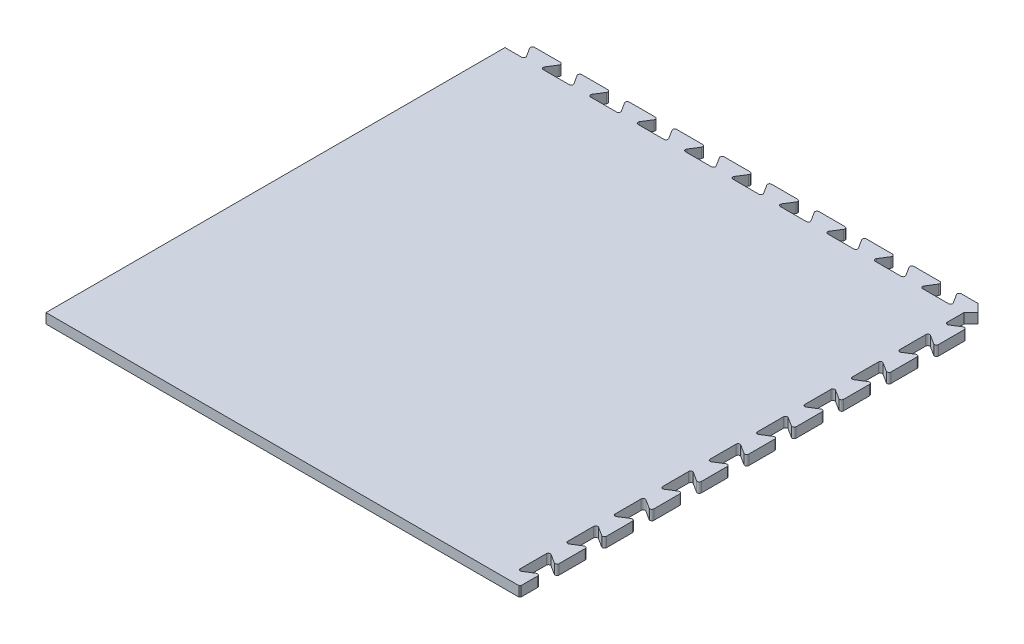
from build123d import *

# Parameters (mm, degrees)
BOSS_EXTRUDE1_DEPTH = 12.7


with BuildPart() as part:
    # Sketch1 → Boss-Extrude1 (new body)
    with BuildSketch(Plane(origin=(0, 12.7, 0), x_dir=(1, 0, 0), z_dir=(0, 1, 0))):
        with BuildLine():
            Line((-270.60420808, 291.891368192), (-291.891368192, 291.891368192))
            Line((-291.891368192, 291.891368192), (-291.891368192, -291.891368192))
            Line((-291.891368192, -291.891368192), (309.78579192, -291.891368192))
            Line((309.78579192, -291.891368192), (310.941368192, -290.73579192))
            Line((310.941368192, -290.73579192), (310.941368192, -269.46329192))
            ThreePointArc((310.941368192, -269.46329192), (309.624423913, -267.237143968), (307.039214883, -267.319431298))
            Line((307.039214883, -267.319431298), (295.793521501, -274.464652541))
            ThreePointArc((295.793521501, -274.464652541), (293.208312471, -274.546939871), (291.891368192, -272.32079192))
            Line((291.891368192, -272.32079192), (291.891368192, -239.30079192))
            ThreePointArc((291.891368192, -239.30079192), (293.208312471, -237.074643968), (295.793521501, -237.156931298))
            Line((295.793521501, -237.156931298), (307.039214883, -244.302152541))
            ThreePointArc((307.039214883, -244.302152541), (309.624423913, -244.384439871), (310.941368192, -242.15829192))
            Line((310.941368192, -242.15829192), (310.941368192, -209.13829192))
            ThreePointArc((310.941368192, -209.13829192), (309.624423913, -206.912143968), (307.039214883, -206.994431298))
            Line((307.039214883, -206.994431298), (295.793521501, -214.139652541))
            ThreePointArc((295.793521501, -214.139652541), (293.208312471, -214.221939871), (291.891368192, -211.99579192))
            Line((291.891368192, -211.99579192), (291.891368192, -178.97579192))
            ThreePointArc((291.891368192, -178.97579192), (293.208312471, -176.749643968), (295.793521501, -176.831931298))
            Line((295.793521501, -176.831931298), (307.039214883, -183.977152541))
            ThreePointArc((307.039214883, -183.977152541), (309.624423913, -184.059439871), (310.941368192, -181.83329192))
            Line((310.941368192, -181.83329192), (310.941368192, -148.81329192))
            ThreePointArc((310.941368192, -148.81329192), (309.624423913, -146.587143968), (307.039214883, -146.669431298))
            Line((307.039214883, -146.669431298), (295.793521501, -153.814652541))
            ThreePointArc((295.793521501, -153.814652541), (293.208312471, -153.896939871), (291.891368192, -151.67079192))
            Line((291.891368192, -151.67079192), (291.891368192, -118.65079192))
            ThreePointArc((291.891368192, -118.65079192), (293.208312471, -116.424643968), (295.793521501, -116.506931298))
            Line((295.793521501, -116.506931298), (307.039214883, -123.652152541))
            ThreePointArc((307.039214883, -123.652152541), (309.624423913, -123.734439871), (310.941368192, -121.50829192))
            Line((310.941368192, -121.50829192), (310.941368192, -88.48829192))
            ThreePointArc((310.941368192, -88.48829192), (309.624423913, -86.262143968), (307.039214883, -86.344431298))
            Line((307.039214883, -86.344431298), (295.793521501, -93.489652541))
            ThreePointArc((295.793521501, -93.489652541), (293.208312471, -93.571939871), (291.891368192, -91.34579192))
            Line((291.891368192, -91.34579192), (291.891368192, -58.32579192))
            ThreePointArc((291.891368192, -58.32579192), (293.208312471, -56.099643968), (295.793521501, -56.181931298))
            Line((295.793521501, -56.181931298), (307.039214883, -63.327152541))
            ThreePointArc((307.039214883, -63.327152541), (309.624423913, -63.409439871), (310.941368192, -61.18329192))
            Line((310.941368192, -61.18329192), (310.941368192, -28.16329192))
            ThreePointArc((310.941368192, -28.16329192), (309.624423913, -25.937143968), (307.039214883, -26.019431298))
            Line((307.039214883, -26.019431298), (295.793521501, -33.164652541))
            ThreePointArc((295.793521501, -33.164652541), (293.208312471, -33.246939871), (291.891368192, -31.02079192))
            Line((291.891368192, -31.02079192), (291.891368192, 1.99920808))
            ThreePointArc((291.891368192, 1.99920808), (293.208312471, 4.225356032), (295.793521501, 4.143068702))
            Line((295.793521501, 4.143068702), (307.039214883, -3.002152541))
            ThreePointArc((307.039214883, -3.002152541), (309.624423913, -3.084439871), (310.941368192, -0.85829192))
            Line((310.941368192, -0.85829192), (310.941368192, 32.16170808))
            ThreePointArc((310.941368192, 32.16170808), (309.624423913, 34.387856032), (307.039214883, 34.305568702))
            Line((307.039214883, 34.305568702), (295.793521501, 27.160347459))
            ThreePointArc((295.793521501, 27.160347459), (293.208312471, 27.078060129), (291.891368192, 29.30420808))
            Line((291.891368192, 29.30420808), (291.891368192, 62.32420808))
            ThreePointArc((291.891368192, 62.32420808), (293.208312471, 64.550356032), (295.793521501, 64.468068702))
            Line((295.793521501, 64.468068702), (307.039214883, 57.322847459))
            ThreePointArc((307.039214883, 57.322847459), (309.624423913, 57.240560129), (310.941368192, 59.46670808))
            Line((310.941368192, 59.46670808), (310.941368192, 92.48670808))
            ThreePointArc((310.941368192, 92.48670808), (309.624423913, 94.712856032), (307.039214883, 94.630568702))
            Line((307.039214883, 94.630568702), (295.793521501, 87.485347459))
            ThreePointArc((295.793521501, 87.485347459), (293.208312471, 87.403060129), (291.891368192, 89.62920808))
            Line((291.891368192, 89.62920808), (291.891368192, 122.64920808))
            ThreePointArc((291.891368192, 122.64920808), (293.208312471, 124.875356032), (295.793521501, 124.793068702))
            Line((295.793521501, 124.793068702), (307.039214883, 117.647847459))
            ThreePointArc((307.039214883, 117.647847459), (309.624423913, 117.565560129), (310.941368192, 119.79170808))
            Line((310.941368192, 119.79170808), (310.941368192, 152.81170808))
            ThreePointArc((310.941368192, 152.81170808), (309.624423913, 155.037856032), (307.039214883, 154.955568702))
            Line((307.039214883, 154.955568702), (295.793521501, 147.810347459))
            ThreePointArc((295.793521501, 147.810347459), (293.208312471, 147.728060129), (291.891368192, 149.95420808))
            Line((291.891368192, 149.95420808), (291.891368192, 182.97420808))
            ThreePointArc((291.891368192, 182.97420808), (293.208312471, 185.200356032), (295.793521501, 185.118068702))
            Line((295.793521501, 185.118068702), (307.039214883, 177.972847459))
            ThreePointArc((307.039214883, 177.972847459), (309.624423913, 177.890560129), (310.941368192, 180.11670808))
            Line((310.941368192, 180.11670808), (310.941368192, 213.13670808))
            ThreePointArc((310.941368192, 213.13670808), (309.624423913, 215.362856032), (307.039214883, 215.280568702))
            Line((307.039214883, 215.280568702), (295.793521501, 208.135347459))
            ThreePointArc((295.793521501, 208.135347459), (293.208312471, 208.053060129), (291.891368192, 210.27920808))
            Line((291.891368192, 210.27920808), (291.891368192, 243.29920808))
            ThreePointArc((291.891368192, 243.29920808), (293.208312471, 245.525356032), (295.793521501, 245.443068702))
            Line((295.793521501, 245.443068702), (307.039214883, 238.297847459))
            ThreePointArc((307.039214883, 238.297847459), (309.624423913, 238.215560129), (310.941368192, 240.44170808))
            Line((310.941368192, 240.44170808), (310.941368192, 273.46170808))
            ThreePointArc((310.941368192, 273.46170808), (309.624423913, 275.687856032), (307.039214883, 275.605568702))
            Line((307.039214883, 275.605568702), (295.793521501, 268.460347459))
            ThreePointArc((295.793521501, 268.460347459), (293.208312471, 268.378060129), (291.891368192, 270.60420808))
            Line((291.891368192, 270.60420808), (291.891368192, 291.891368192))
            Line((291.891368192, 291.891368192), (300.838580056, 300.838580056))
            Line((300.838580056, 300.838580056), (290.73579192, 310.941368192))
            Line((290.73579192, 310.941368192), (269.46329192, 310.941368192))
            ThreePointArc((269.46329192, 310.941368192), (267.237143968, 309.624423913), (267.319431298, 307.039214883))
            Line((267.319431298, 307.039214883), (274.464652541, 295.793521501))
            ThreePointArc((274.464652541, 295.793521501), (274.546939871, 293.208312471), (272.32079192, 291.891368192))
            Line((272.32079192, 291.891368192), (239.30079192, 291.891368192))
            ThreePointArc((239.30079192, 291.891368192), (237.074643968, 293.208312471), (237.156931298, 295.793521501))
            Line((237.156931298, 295.793521501), (244.302152541, 307.039214883))
            ThreePointArc((244.302152541, 307.039214883), (244.384439871, 309.624423913), (242.15829192, 310.941368192))
            Line((242.15829192, 310.941368192), (209.13829192, 310.941368192))
            ThreePointArc((209.13829192, 310.941368192), (206.912143968, 309.624423913), (206.994431298, 307.039214883))
            Line((206.994431298, 307.039214883), (214.139652541, 295.793521501))
            ThreePointArc((214.139652541, 295.793521501), (214.221939871, 293.208312471), (211.99579192, 291.891368192))
            Line((211.99579192, 291.891368192), (178.97579192, 291.891368192))
            ThreePointArc((178.97579192, 291.891368192), (176.749643968, 293.208312471), (176.831931298, 295.793521501))
            Line((176.831931298, 295.793521501), (183.977152541, 307.039214883))
            ThreePointArc((183.977152541, 307.039214883), (184.059439871, 309.624423913), (181.83329192, 310.941368192))
            Line((181.83329192, 310.941368192), (148.81329192, 310.941368192))
            ThreePointArc((148.81329192, 310.941368192), (146.587143968, 309.624423913), (146.669431298, 307.039214883))
            Line((146.669431298, 307.039214883), (153.814652541, 295.793521501))
            ThreePointArc((153.814652541, 295.793521501), (153.896939871, 293.208312471), (151.67079192, 291.891368192))
            Line((151.67079192, 291.891368192), (118.65079192, 291.891368192))
            ThreePointArc((118.65079192, 291.891368192), (116.424643968, 293.208312471), (116.506931298, 295.793521501))
            Line((116.506931298, 295.793521501), (123.652152541, 307.039214883))
            ThreePointArc((123.652152541, 307.039214883), (123.734439871, 309.624423913), (121.50829192, 310.941368192))
            Line((121.50829192, 310.941368192), (88.48829192, 310.941368192))
            ThreePointArc((88.48829192, 310.941368192), (86.262143968, 309.624423913), (86.344431298, 307.039214883))
            Line((86.344431298, 307.039214883), (93.489652541, 295.793521501))
            ThreePointArc((93.489652541, 295.793521501), (93.571939871, 293.208312471), (91.34579192, 291.891368192))
            Line((91.34579192, 291.891368192), (58.32579192, 291.891368192))
            ThreePointArc((58.32579192, 291.891368192), (56.099643968, 293.208312471), (56.181931298, 295.793521501))
            Line((56.181931298, 295.793521501), (63.327152541, 307.039214883))
            ThreePointArc((63.327152541, 307.039214883), (63.409439871, 309.624423913), (61.18329192, 310.941368192))
            Line((61.18329192, 310.941368192), (28.16329192, 310.941368192))
            ThreePointArc((28.16329192, 310.941368192), (25.937143968, 309.624423913), (26.019431298, 307.039214883))
            Line((26.019431298, 307.039214883), (33.164652541, 295.793521501))
            ThreePointArc((33.164652541, 295.793521501), (33.246939871, 293.208312471), (31.02079192, 291.891368192))
            Line((31.02079192, 291.891368192), (-1.99920808, 291.891368192))
            ThreePointArc((-1.99920808, 291.891368192), (-4.225356032, 293.208312471), (-4.143068702, 295.793521501))
            Line((-4.143068702, 295.793521501), (3.002152541, 307.039214883))
            ThreePointArc((3.002152541, 307.039214883), (3.084439871, 309.624423913), (0.85829192, 310.941368192))
            Line((0.85829192, 310.941368192), (-32.16170808, 310.941368192))
            ThreePointArc((-32.16170808, 310.941368192), (-34.387856032, 309.624423913), (-34.305568702, 307.039214883))
            Line((-34.305568702, 307.039214883), (-27.160347459, 295.793521501))
            ThreePointArc((-27.160347459, 295.793521501), (-27.078060129, 293.208312471), (-29.30420808, 291.891368192))
            Line((-29.30420808, 291.891368192), (-62.32420808, 291.891368192))
            ThreePointArc((-62.32420808, 291.891368192), (-64.550356032, 293.208312471), (-64.468068702, 295.793521501))
            Line((-64.468068702, 295.793521501), (-57.322847459, 307.039214883))
            ThreePointArc((-57.322847459, 307.039214883), (-57.240560129, 309.624423913), (-59.46670808, 310.941368192))
            Line((-59.46670808, 310.941368192), (-92.48670808, 310.941368192))
            ThreePointArc((-92.48670808, 310.941368192), (-94.712856032, 309.624423913), (-94.630568702, 307.039214883))
            Line((-94.630568702, 307.039214883), (-87.485347459, 295.793521501))
            ThreePointArc((-87.485347459, 295.793521501), (-87.403060129, 293.208312471), (-89.62920808, 291.891368192))
            Line((-89.62920808, 291.891368192), (-122.64920808, 291.891368192))
            ThreePointArc((-122.64920808, 291.891368192), (-124.875356032, 293.208312471), (-124.793068702, 295.793521501))
            Line((-124.793068702, 295.793521501), (-117.647847459, 307.039214883))
            ThreePointArc((-117.647847459, 307.039214883), (-117.565560129, 309.624423913), (-119.79170808, 310.941368192))
            Line((-119.79170808, 310.941368192), (-152.81170808, 310.941368192))
            ThreePointArc((-152.81170808, 310.941368192), (-155.037856032, 309.624423913), (-154.955568702, 307.039214883))
            Line((-154.955568702, 307.039214883), (-147.810347459, 295.793521501))
            ThreePointArc((-147.810347459, 295.793521501), (-147.728060129, 293.208312471), (-149.95420808, 291.891368192))
            Line((-149.95420808, 291.891368192), (-182.97420808, 291.891368192))
            ThreePointArc((-182.97420808, 291.891368192), (-185.200356032, 293.208312471), (-185.118068702, 295.793521501))
            Line((-185.118068702, 295.793521501), (-177.972847459, 307.039214883))
            ThreePointArc((-177.972847459, 307.039214883), (-177.890560129, 309.624423913), (-180.11670808, 310.941368192))
            Line((-180.11670808, 310.941368192), (-213.13670808, 310.941368192))
            ThreePointArc((-213.13670808, 310.941368192), (-215.362856032, 309.624423913), (-215.280568702, 307.039214883))
            Line((-215.280568702, 307.039214883), (-208.135347459, 295.793521501))
            ThreePointArc((-208.135347459, 295.793521501), (-208.053060129, 293.208312471), (-210.27920808, 291.891368192))
            Line((-210.27920808, 291.891368192), (-243.29920808, 291.891368192))
            ThreePointArc((-243.29920808, 291.891368192), (-245.525356032, 293.208312471), (-245.443068702, 295.793521501))
            Line((-245.443068702, 295.793521501), (-238.297847459, 307.039214883))
            ThreePointArc((-238.297847459, 307.039214883), (-238.215560129, 309.624423913), (-240.44170808, 310.941368192))
            Line((-240.44170808, 310.941368192), (-273.46170808, 310.941368192))
            ThreePointArc((-273.46170808, 310.941368192), (-275.687856032, 309.624423913), (-275.605568702, 307.039214883))
            Line((-275.605568702, 307.039214883), (-268.460347459, 295.793521501))
            ThreePointArc((-268.460347459, 295.793521501), (-268.378060129, 293.208312471), (-270.60420808, 291.891368192))
        make_face()
    extrude(amount=-BOSS_EXTRUDE1_DEPTH)


solid = part.part
